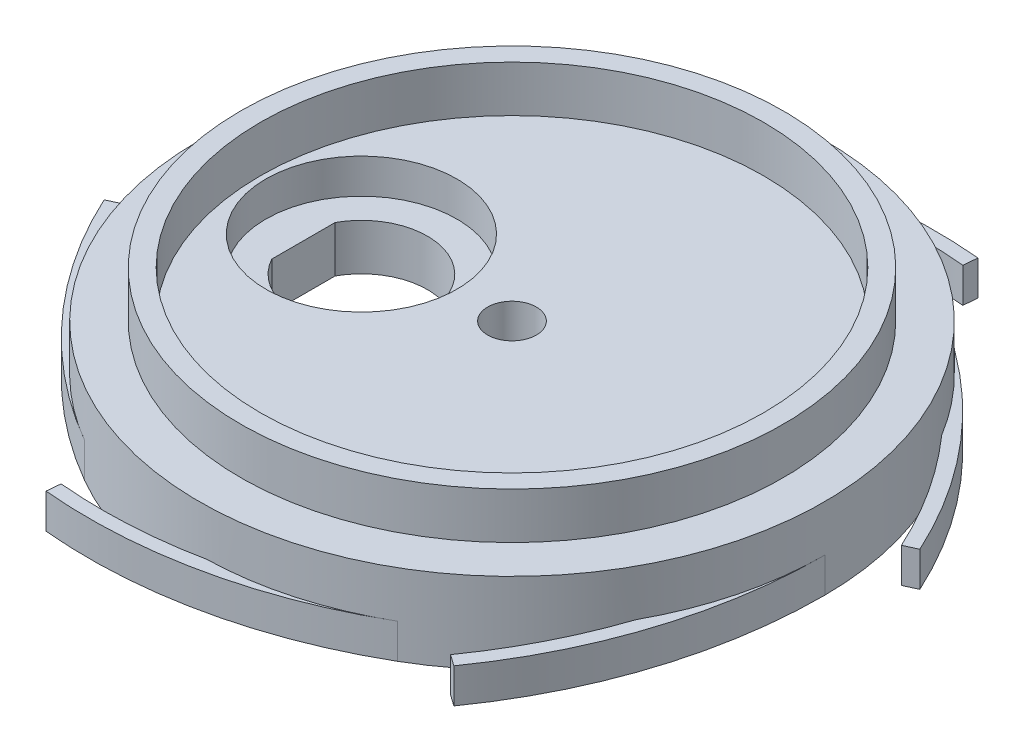
from build123d import *

# Parameters (mm, degrees)
BOSS_EXTRUDE1_DEPTH        = 3
F_4_2_4_2_DIAMETER_HOLE1_D = 4.2
SKETCH24_R                 = 1
CUT_EXTRUDE3_DEPTH         = 10
SKETCH25_R                 = 8.25
CUT_EXTRUDE4_DEPTH         = 3


with BuildPart() as part:
    # Sketch1 → Revolve1 (revolve)
    with BuildSketch(Plane.XY):
        Polygon((-23.425, 0), (-23.425, -4), (-27, -4), (-27, -8), (0, -8), (0, -4), (-21.721500416, -4), (-21.721500416, 0), align=None)
    revolve(axis=Axis((0, -8, 0), (0, -1, 0)))

    # Sketch18 → Boss-Extrude1 (add)
    with BuildSketch(Plane.XZ.offset(8)):
        with BuildLine():
            Line((18.287619048, 23.591829478), (19.266666667, 24.285706816))
            ThreePointArc((19.266666667, 24.285706816), (25.019995002, 12.743625858), (27, 0))
            ThreePointArc((27, 0), (25.997622732, -7.288594671), (23.06491761, -14.036009962))
            ThreePointArc((23.06491761, -14.036009962), (26.687121428, -9.277998508), (29.574933174, -4.041627931))
            Line((29.574933174, -4.041627931), (30.665372385, -4.542569372))
            ThreePointArc((30.665372385, -4.542569372), (23.54630123, -15.296138346), (13.5, -23.382685902))
            ThreePointArc((13.5, -23.382685902), (6.686703224, -26.158899059), (-0.62308239, -26.992809567))
            ThreePointArc((-0.62308239, -26.992809567), (5.30857831, -27.750724365), (11.287314126, -27.633457409))
            Line((11.287314126, -27.633457409), (11.398705718, -28.828276188))
            ThreePointArc((11.398705718, -28.828276188), (-1.473693772, -28.039764204), (-13.5, -23.382685902))
            ThreePointArc((-13.5, -23.382685902), (-19.310919509, -18.870304389), (-23.688, -12.956799605))
            ThreePointArc((-23.688, -12.956799605), (-21.378543119, -18.472725857), (-18.287619048, -23.591829478))
            Line((-18.287619048, -23.591829478), (-19.266666667, -24.285706816))
            ThreePointArc((-19.266666667, -24.285706816), (-25.019995002, -12.743625858), (-27, 0))
            ThreePointArc((-27, 0), (-25.997622732, 7.288594671), (-23.06491761, 14.036009962))
            ThreePointArc((-23.06491761, 14.036009962), (-26.687121428, 9.277998508), (-29.574933174, 4.041627931))
            Line((-29.574933174, 4.041627931), (-30.665372385, 4.542569372))
            ThreePointArc((-30.665372385, 4.542569372), (-23.54630123, 15.296138346), (-13.5, 23.382685902))
            ThreePointArc((-13.5, 23.382685902), (-6.686703224, 26.158899059), (0.62308239, 26.992809567))
            ThreePointArc((0.62308239, 26.992809567), (-5.30857831, 27.750724365), (-11.287314126, 27.633457409))
            Line((-11.287314126, 27.633457409), (-11.398705718, 28.828276188))
            ThreePointArc((-11.398705718, 28.828276188), (1.473693772, 28.039764204), (13.5, 23.382685902))
            ThreePointArc((13.5, 23.382685902), (19.310919509, 18.870304389), (23.688, 12.956799605))
            ThreePointArc((23.688, 12.956799605), (21.378543119, 18.472725857), (18.287619048, 23.591829478))
        make_face()
    extrude(amount=BOSS_EXTRUDE1_DEPTH)

    # Ø4.2 (4.2) Diameter Hole1 (through all)
    with Locations(Plane(origin=(0, -4, 0), x_dir=(1, 0, 0), z_dir=(0, 1, 0))):
        with Locations((0, 0)):
            Hole(F_4_2_4_2_DIAMETER_HOLE1_D / 2)

    # Sketch24 → Cut-Extrude3 (cut)
    with BuildSketch(Plane.XZ.offset(11)):
        with BuildLine():
            ThreePointArc((-7.3, 0), (-11.587555311, 5.522227811), (-18, 2.736786437))
            Line((-18, 2.736786437), (-18, -2.736786437))
            ThreePointArc((-18, -2.736786437), (-11.587555311, -5.522227811), (-7.3, 0))
        make_face()
        with Locations((20, 0)):
            Circle(SKETCH24_R)
    extrude(amount=-CUT_EXTRUDE3_DEPTH, mode=Mode.SUBTRACT)

    # Sketch25 → Cut-Extrude4 (cut)
    with BuildSketch(Plane(origin=(0, -4, 0), x_dir=(1, 0, 0), z_dir=(0, 1, 0))):
        with Locations((-13, 0)):
            Circle(SKETCH25_R)
    extrude(amount=-CUT_EXTRUDE4_DEPTH, mode=Mode.SUBTRACT)


solid = part.part
